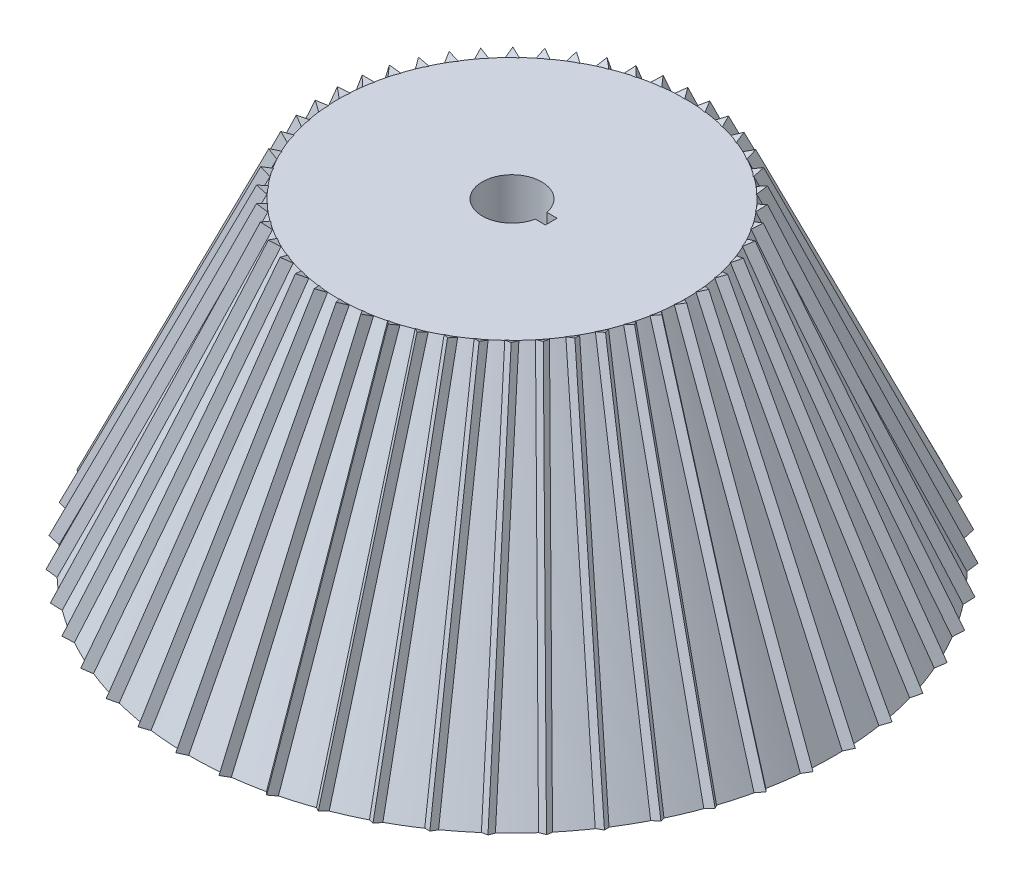
from build123d import *

# Parameters (mm, degrees)
CUT_EXTRUDE1_DEPTH = 102
CIRPATTERN1_COUNT  = 50


with BuildPart() as part:
    # Sketch1 → Revolve1 (revolve)
    with BuildSketch(Plane.XY):
        Polygon((0, 0), (65, 0), (35, 65), (0, 65), align=None)
    revolve(axis=Axis((0, 65, 0), (0, -1, 0)))

    # Sketch2 → Cut-Extrude1 (cut)
    with BuildSketch(Plane(origin=(0, 65, 0), x_dir=(1, 0, 0), z_dir=(0, 1, 0))):
        with BuildLine():
            Line((5.881320272, -1.187464466), (7.929739849, -1.187464466))
            Line((7.929739849, -1.187464466), (7.929739849, 1.187464466))
            Line((7.929739849, 1.187464466), (5.881320272, 1.187464466))
            ThreePointArc((5.881320272, 1.187464466), (-6, 0), (5.881320272, -1.187464466))
        make_face()
    extrude(amount=-CUT_EXTRUDE1_DEPTH, mode=Mode.SUBTRACT)

    # Sweep1: sweep along a curve in space
    with BuildLine() as sweep1_path:
        Line((34.84919126, 65, -3.245592172), (64.941506163, 0, -2.756950733))
    # Sketch3 → Sweep1 (sweep)
    with BuildSketch(Plane(origin=(34.84919126, 65, -3.245592172), x_dir=(-0.907472911, -0.420098729, 0.003158118), z_dir=(0.4201106, -0.90744727, 0.00682179))):
        Polygon((0.929922034, 1.461247758), (-1.730438697, 0.074712226), (0.800516662, -1.535959984), align=None)
    sweep1 = sweep(path=sweep1_path.line)

    # CirPattern1: Sweep1 ×50 about axis
    cirpattern1_axis = Axis((0, 0, 0), (0, 1, 0))
    for i in range(1, CIRPATTERN1_COUNT):
        add(sweep1.rotate(cirpattern1_axis, i * 360 / CIRPATTERN1_COUNT))


solid = part.part
